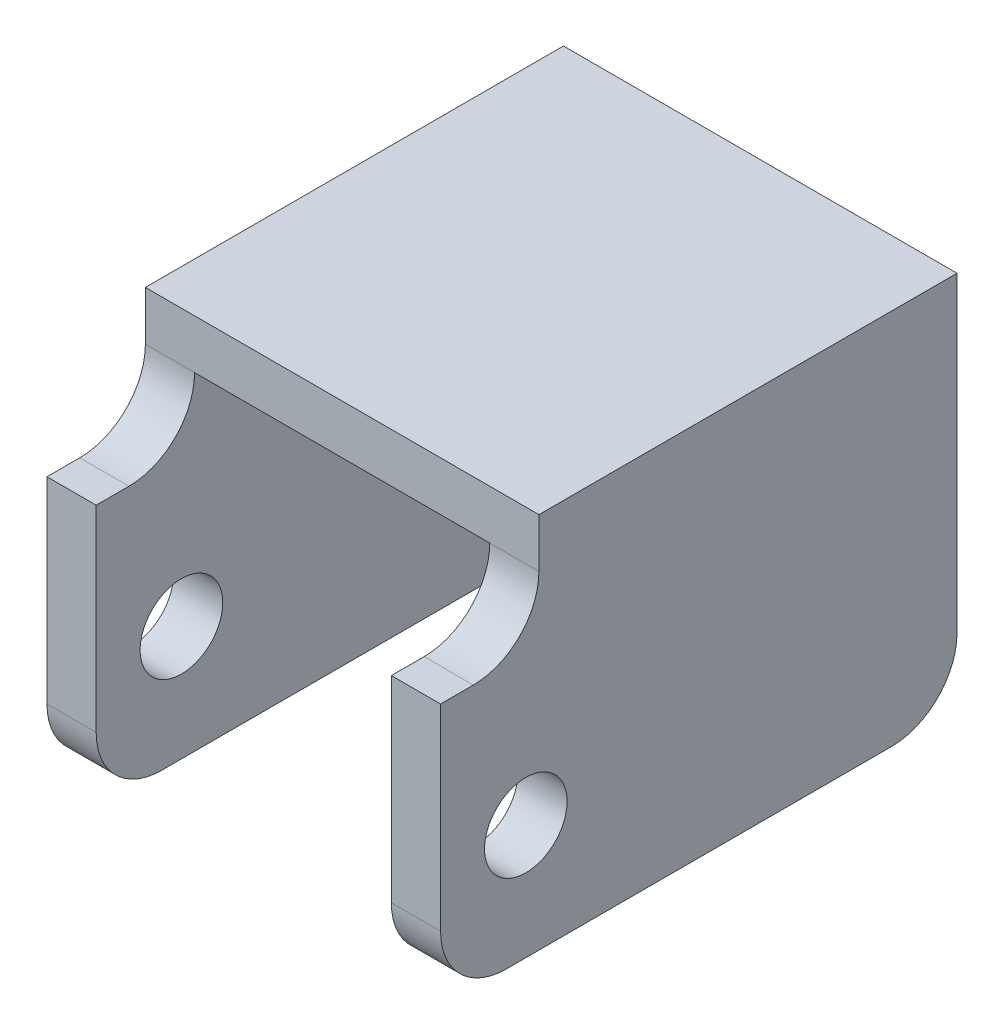
from build123d import *

# Parameters (mm, degrees)
SKETCH1_W           = 4.7625
SKETCH1_H           = 50
SKETCH1_W_2         = 28.575
BOSS_EXTRUDE1_DEPTH = 4.7625
SKETCH1_3_W         = 4.7625
SKETCH1_3_H         = 50
BOSS_EXTRUDE2_DEPTH = 31.75
SKETCH3_W           = 9.525
SKETCH3_H           = 11.1125
SKETCH3_R           = 4
CUT_EXTRUDE1_DEPTH  = 39.1
FILLET1_R           = 6.35


with BuildPart() as part:
    # Sketch1 → Boss-Extrude1 (new body)
    with BuildSketch(Plane(origin=(0, 0, 0), x_dir=(1, 0, 0), z_dir=(0, 1, 0))):
        with Locations((-16.66875, 0)):
            Rectangle(SKETCH1_W, SKETCH1_H)
        Rectangle(SKETCH1_W_2, SKETCH1_H)
        with Locations((16.66875, 0)):
            Rectangle(SKETCH1_W, SKETCH1_H)
    extrude(amount=BOSS_EXTRUDE1_DEPTH)

    # Sketch1_3 → Boss-Extrude2 (add)
    with BuildSketch(Plane(origin=(0, 0, 0), x_dir=(1, 0, 0), z_dir=(0, 1, 0))):
        with Locations((-16.66875, 0)):
            Rectangle(SKETCH1_3_W, SKETCH1_3_H)
        with Locations((16.66875, 0)):
            Rectangle(SKETCH1_3_W, SKETCH1_3_H)
    extrude(amount=-BOSS_EXTRUDE2_DEPTH)

    # Sketch3 → Cut-Extrude1 (cut, through all)
    with BuildSketch(Plane(origin=(19.05, 0, 0), x_dir=(0, 0, -1), z_dir=(1, 0, 0))):
        with Locations((-20.2375, -0.79375)):
            Rectangle(SKETCH3_W, SKETCH3_H)
        with Locations((-16.745, -20.6375)):
            Circle(SKETCH3_R)
    extrude(amount=-CUT_EXTRUDE1_DEPTH, mode=Mode.SUBTRACT)

    # Fillet1
    fillet1_edges = [part.edges().sort_by_distance(p)[0] for p in [
        (-16.66875, -31.75, 25),
        (16.66875, -31.75, 25),
        (-16.66875, -31.75, -25),
        (16.66875, -31.75, -25),
        (-16.66875, -6.35, 15.475),
        (16.66875, -6.35, 15.475),
    ]]
    fillet(fillet1_edges, radius=FILLET1_R)


solid = part.part
